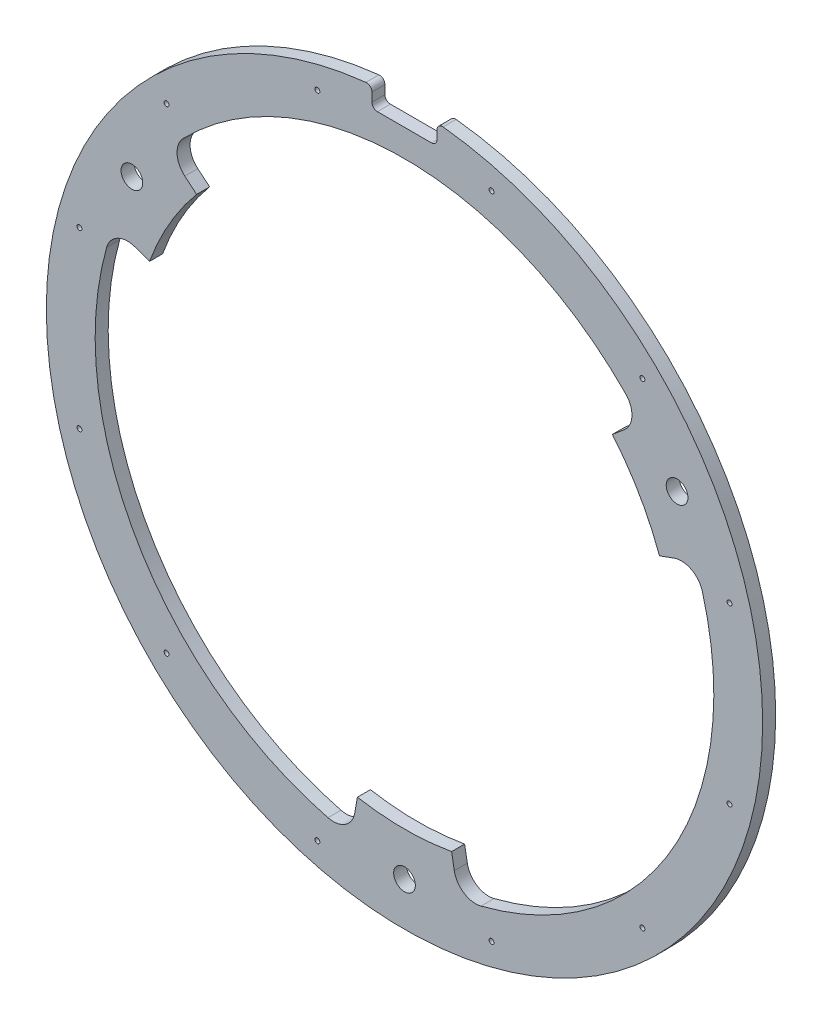
from build123d import *

# Parameters (mm, degrees)
SKETCH2_R                                      = 330
SKETCH2_R_2                                    = 250
BOSS_EXTRUDE1_DEPTH                            = 12
CUT_EXTRUDE1_DEPTH                             = 12
SKETCH4_R                                      = 10
CUT_EXTRUDE2_DEPTH                             = 12
SKETCH5_W                                      = 60
SKETCH5_H                                      = 60
CUT_EXTRUDE3_DEPTH                             = 12
FILLET1_R                                      = 5
CSK_FOR_M4_FLAT_HEAD_MACHINE_SCREW_D           = 4.5
CSK_FOR_M4_FLAT_HEAD_MACHINE_SCREW_CSINK_D     = 9.4
CSK_FOR_M4_FLAT_HEAD_MACHINE_SCREW_CSINK_ANGLE = 90


with BuildPart() as part:
    # Sketch2 → Boss-Extrude1 (new body)
    with BuildSketch(Plane.XY):
        Circle(SKETCH2_R)
        Circle(SKETCH2_R_2, mode=Mode.SUBTRACT)
    extrude(amount=BOSS_EXTRUDE1_DEPTH)

    # Sketch3 → Cut-Extrude1 (cut)
    with BuildSketch(Plane.XY.offset(12)):
        with BuildLine():
            Line((191.51111078, 160.696902422), (202.422805046, 169.852901056))
            ThreePointArc((202.422805046, 169.852901056), (209.542560602, 184.184300077), (203.874000238, 199.14917029))
            ThreePointArc((203.874000238, 199.14917029), (0, 285), (-203.874000238, 199.14917029))
            ThreePointArc((-203.874000238, 199.14917029), (-209.542560602, 184.184300077), (-202.422805046, 169.852901056))
            Line((-202.422805046, 169.852901056), (-191.51111078, 160.696902422))
            ThreePointArc((-191.51111078, 160.696902422), (0, 250), (191.51111078, 160.696902422))
        make_face()
        with BuildLine():
            Line((43.412044417, -246.201938253), (45.885524698, -260.229742003))
            ThreePointArc((45.885524698, -260.229742003), (54.737002544, -273.561330694), (70.531240495, -276.134648522))
            ThreePointArc((70.531240495, -276.134648522), (246.817240079, -142.5), (274.405240732, 76.985478232))
            ThreePointArc((274.405240732, 76.985478232), (264.279563146, 89.377030617), (248.308329744, 90.376840947))
            Line((248.308329744, 90.376840947), (234.923155196, 85.505035831))
            ThreePointArc((234.923155196, 85.505035831), (216.506350946, -125), (43.412044417, -246.201938253))
        make_face()
        with BuildLine():
            Line((-234.923155196, 85.505035831), (-248.308329744, 90.376840947))
            ThreePointArc((-248.308329744, 90.376840947), (-264.279563146, 89.377030617), (-274.405240732, 76.985478232))
            ThreePointArc((-274.405240732, 76.985478232), (-246.817240079, -142.5), (-70.531240495, -276.134648522))
            ThreePointArc((-70.531240495, -276.134648522), (-54.737002544, -273.561330694), (-45.885524698, -260.229742003))
            Line((-45.885524698, -260.229742003), (-43.412044417, -246.201938253))
            ThreePointArc((-43.412044417, -246.201938253), (-216.506350946, -125), (-234.923155196, 85.505035831))
        make_face()
    extrude(amount=-CUT_EXTRUDE1_DEPTH, mode=Mode.SUBTRACT)

    # Sketch4 → Cut-Extrude2 (cut)
    with BuildSketch(Plane.XY.offset(12)):
        with Locations((0, -290)):
            Circle(SKETCH4_R)
        with Locations((-251.147367097, 145)):
            Circle(SKETCH4_R)
        with Locations((251.147367097, 145)):
            Circle(SKETCH4_R)
    extrude(amount=-CUT_EXTRUDE2_DEPTH, mode=Mode.SUBTRACT)

    # Sketch5 → Cut-Extrude3 (cut)
    with BuildSketch(Plane.XY.offset(12)):
        with Locations((0, 340)):
            Rectangle(SKETCH5_W, SKETCH5_H)
    extrude(amount=-CUT_EXTRUDE3_DEPTH, mode=Mode.SUBTRACT)

    # Fillet1
    fillet1_edges = [part.edges().sort_by_distance(p)[0] for p in [
        (30, 328.633534503, 6),
        (-30, 328.633534503, 6),
        (-30, 310, 6),
        (30, 310, 6),
    ]]
    fillet(fillet1_edges, radius=FILLET1_R)

    # CSK for M4 Flat Head Machine Screw (through all)
    with Locations(Plane(origin=(0, 0, -24), x_dir=(1, 0, 0), z_dir=(0, 0, -1))):
        with Locations((80.233903982, 299.43700615), (219.203102168, 219.203102168), (299.43700615, 80.233903982), (299.43700615, -80.233903982), (219.203102168, -219.203102168), (80.233903982, -299.43700615), (-80.233903982, -299.43700615), (-219.203102168, -219.203102168), (-299.43700615, -80.233903982), (-299.43700615, 80.233903982), (-219.203102168, 219.203102168), (-80.233903982, 299.43700615), (0, 0)):
            CounterSinkHole(CSK_FOR_M4_FLAT_HEAD_MACHINE_SCREW_D / 2, CSK_FOR_M4_FLAT_HEAD_MACHINE_SCREW_CSINK_D / 2, counter_sink_angle=CSK_FOR_M4_FLAT_HEAD_MACHINE_SCREW_CSINK_ANGLE)


solid = part.part
